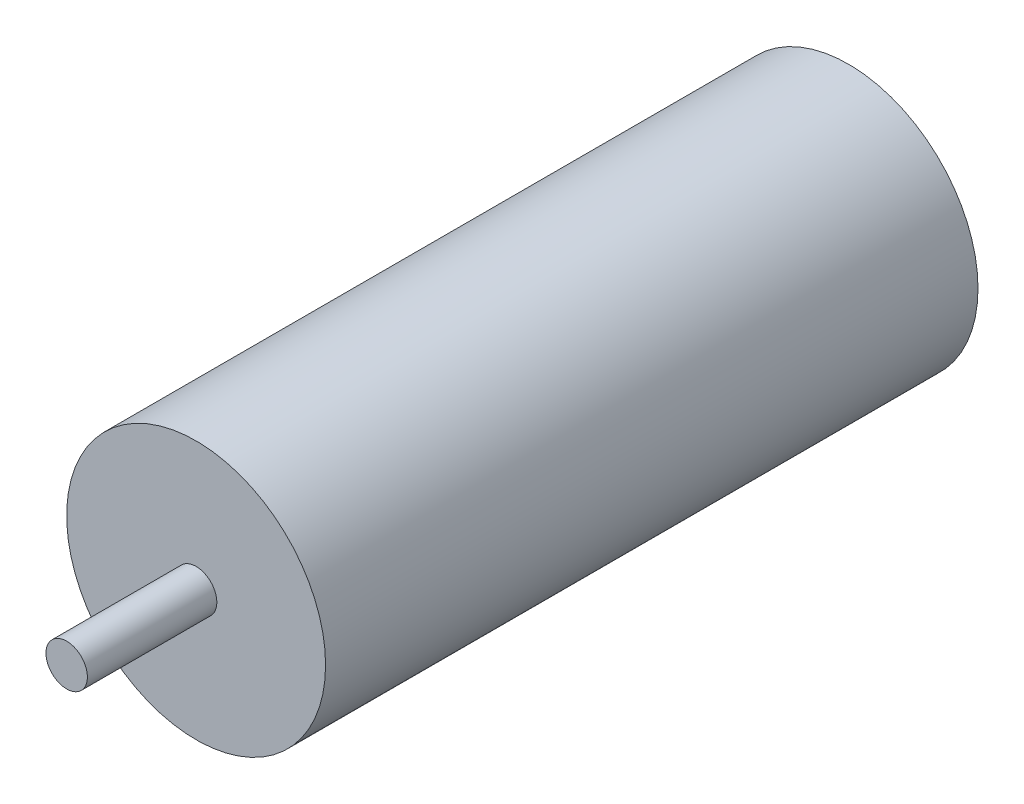
from build123d import *

# Parameters (mm, degrees)
SKETCH1_R           = 12.5
BOSS_EXTRUDE1_DEPTH = 63
SKETCH2_R           = 2
BOSS_EXTRUDE2_DEPTH = 12.5


with BuildPart() as part:
    # Sketch1 → Boss-Extrude1 (new body)
    with BuildSketch(Plane.XY):
        Circle(SKETCH1_R)
    extrude(amount=BOSS_EXTRUDE1_DEPTH)

    # Sketch2 → Boss-Extrude2 (add)
    with BuildSketch(Plane.XY.offset(63)):
        Circle(SKETCH2_R)
    extrude(amount=BOSS_EXTRUDE2_DEPTH)


solid = part.part
